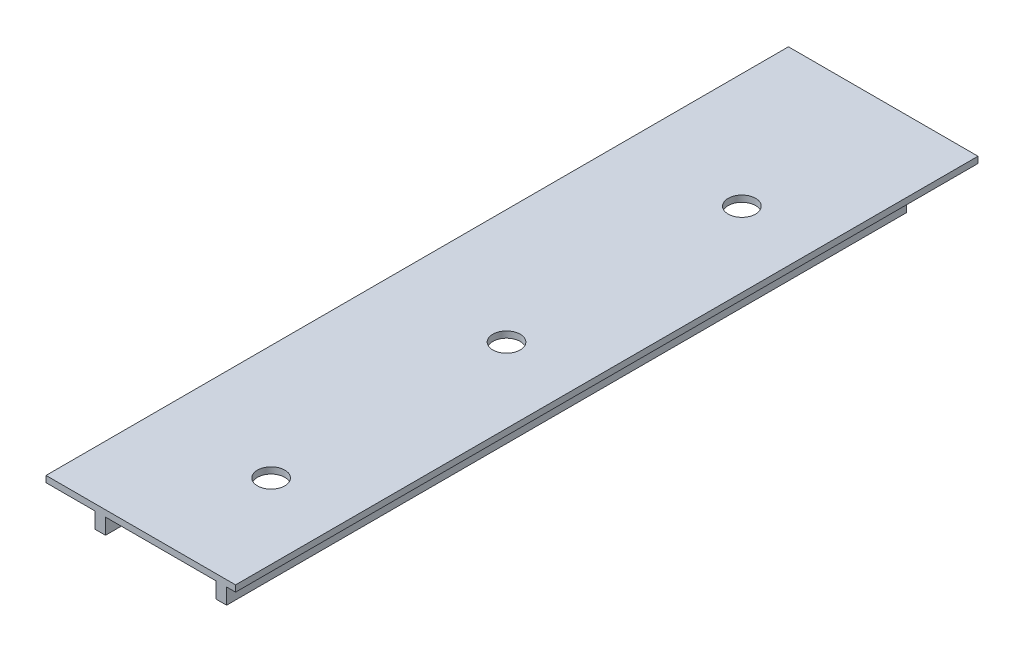
from build123d import *

# Parameters (mm, degrees)
SKETCH1_W           = 18
SKETCH1_H           = 70.5
BOSS_EXTRUDE1_DEPTH = 0.6
SKETCH3_R           = 1.3
CUT_EXTRUDE1_DEPTH  = 10
SKETCH4_W           = 1
SKETCH4_H           = 64.56
BOSS_EXTRUDE2_DEPTH = 1.5


with BuildPart() as part:
    # Sketch1 → Boss-Extrude1 (new body)
    with BuildSketch(Plane(origin=(0, 0, 0), x_dir=(1, 0, 0), z_dir=(0, 1, 0))):
        with Locations((9, 35.25)):
            Rectangle(SKETCH1_W, SKETCH1_H)
    extrude(amount=BOSS_EXTRUDE1_DEPTH)

    # Sketch3 → Cut-Extrude1 (cut)
    with BuildSketch(Plane(origin=(0, 0.6, 0), x_dir=(1, 0, 0), z_dir=(0, 1, 0))):
        with Locations((10.9, 10.48)):
            Circle(SKETCH3_R)
        with Locations((10.9, 32.83)):
            Circle(SKETCH3_R)
        with Locations((10.9, 55.18)):
            Circle(SKETCH3_R)
    extrude(amount=-CUT_EXTRUDE1_DEPTH, mode=Mode.SUBTRACT)

    # Sketch4 → Boss-Extrude2 (add)
    with BuildSketch(Plane.XZ):
        with Locations((5.15, -32.28)):
            Rectangle(SKETCH4_W, SKETCH4_H)
        with Locations((16.65, -32.28)):
            Rectangle(SKETCH4_W, SKETCH4_H)
    extrude(amount=BOSS_EXTRUDE2_DEPTH)


solid = part.part
